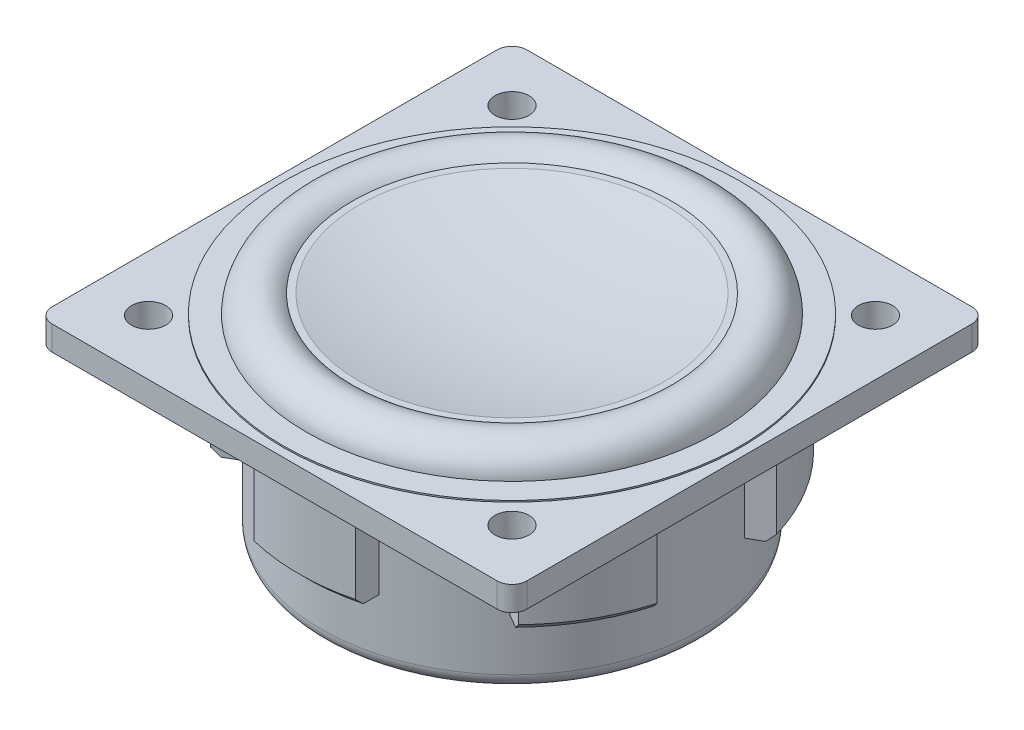
from build123d import *

# Parameters (mm, degrees)
SKETCH_1_W               = 32
SKETCH_1_H               = 32
EXTRUDE_1_DEPTH          = 1.65
SKETCH_3_R               = 12.85
EXTRUDE_2_DEPTH          = 11.25
EXTRUDE_3_DEPTH          = 6.75
PATTERN_CIRCULAR_1_COUNT = 6
FILLET_1_R               = 1
FILLET_2_R               = 1
SKETCH_4_R               = 1.15
CUT_EXTRUDE_2_DEPTH      = 27.04630492
CHAMFER_1_SIZE           = 0.5


with BuildPart() as part:
    # Эскиз1 → Бобышка-Вытянуть1 (new body)
    with BuildSketch(Plane(origin=(0, 0, 0), x_dir=(1, 0, 0), z_dir=(0, 1, 0))):
        Rectangle(SKETCH_1_W, SKETCH_1_H)
    extrude(amount=-EXTRUDE_1_DEPTH)

    # Эскиз2 → Повернуть2 (revolve)
    with BuildSketch(Plane(origin=(0, 0, 0), x_dir=(0, 0, -1), z_dir=(1, 0, 0))):
        with BuildLine():
            Line((0, -1.65), (0, 0))
            ThreePointArc((0, 0), (-5.190857347, 0.326284094), (-10.3, 1.3))
            Line((-10.3, 1.3), (-10.75, 1.3))
            ThreePointArc((-10.75, 1.3), (-12.677691027, 1.675701821), (-13.85, 0.1))
            Line((-13.85, 0.1), (-15.425, 0.1))
            Line((-15.425, 0.1), (-15.425, -1.65))
            Line((-15.425, -1.65), (0, -1.65))
        make_face()
    revolve(axis=Axis((0, 0, 0), (0, -1, 0)))

    # Эскиз3 → Бобышка-Вытянуть2 (add)
    with BuildSketch(Plane.XZ.offset(1.65)):
        Circle(SKETCH_3_R)
    extrude(amount=EXTRUDE_2_DEPTH)

    # Эскиз3<3> → Бобышка-Вытянуть3 (add)
    with BuildSketch(Plane.XZ.offset(1.65)):
        with BuildLine():
            ThreePointArc((-3.425, -13.961017155), (0, -14.375), (3.425, -13.961017155))
            Line((3.425, -13.961017155), (3.425, -12.385147355))
            ThreePointArc((3.425, -12.385147355), (0, -12.85), (-3.425, -12.385147355))
            Line((-3.425, -12.385147355), (-3.425, -13.961017155))
        make_face()
        with BuildLine():
            ThreePointArc((-3.425, 12.385147355), (0, 12.85), (3.425, 12.385147355))
            Line((3.425, 12.385147355), (3.425, 13.961017155))
            ThreePointArc((3.425, 13.961017155), (0, 14.375), (-3.425, 13.961017155))
            Line((-3.425, 13.961017155), (-3.425, 12.385147355))
        make_face()
    extrude_3 = extrude(amount=EXTRUDE_3_DEPTH)

    # Круговой массив1: Бобышка-Вытянуть3 ×6 about axis
    pattern_circular_1_axis = Axis((0, -12.9, 0), (0, 1, 0))
    for i in range(1, PATTERN_CIRCULAR_1_COUNT):
        add(extrude_3.rotate(pattern_circular_1_axis, i * 360 / PATTERN_CIRCULAR_1_COUNT))

    # Скругление1
    fillet_1_edges = [part.edges().sort_by_distance(p)[0] for p in [
        (16, -0.825, 16),
        (16, -0.825, -16),
        (-16, -0.825, -16),
        (-16, -0.825, 16),
    ]]
    fillet(fillet_1_edges, radius=FILLET_1_R)

    # Скругление2
    fillet_2_edges = [part.edges().sort_by_distance(p)[0] for p in [
        (-12.85, -12.9, 0),
    ]]
    fillet(fillet_2_edges, radius=FILLET_2_R)

    # Эскиз4 → Вырез-Вытянуть2 (cut, through all)
    with BuildSketch(Plane(origin=(0, 0, 0), x_dir=(1, 0, 0), z_dir=(0, 1, 0))):
        with Locations((-12.25, 12.25)):
            Circle(SKETCH_4_R)
        with Locations((12.25, 12.25)):
            Circle(SKETCH_4_R)
        with Locations((12.25, -12.25)):
            Circle(SKETCH_4_R)
        with Locations((-12.25, -12.25)):
            Circle(SKETCH_4_R)
    extrude(amount=-CUT_EXTRUDE_2_DEPTH, mode=Mode.SUBTRACT)

    # Фаска1
    chamfer_1_edges = [part.edges().sort_by_distance(p)[0] for p in [
        (0, -8.4, -14.375),
        (12.449115179, -8.4, -7.1875),
        (12.449115179, -8.4, 7.1875),
        (0, -8.4, 14.375),
        (-12.449115179, -8.4, 7.1875),
        (-12.449115179, -8.4, -7.1875),
    ]]
    chamfer(chamfer_1_edges, length=CHAMFER_1_SIZE)


solid = part.part
